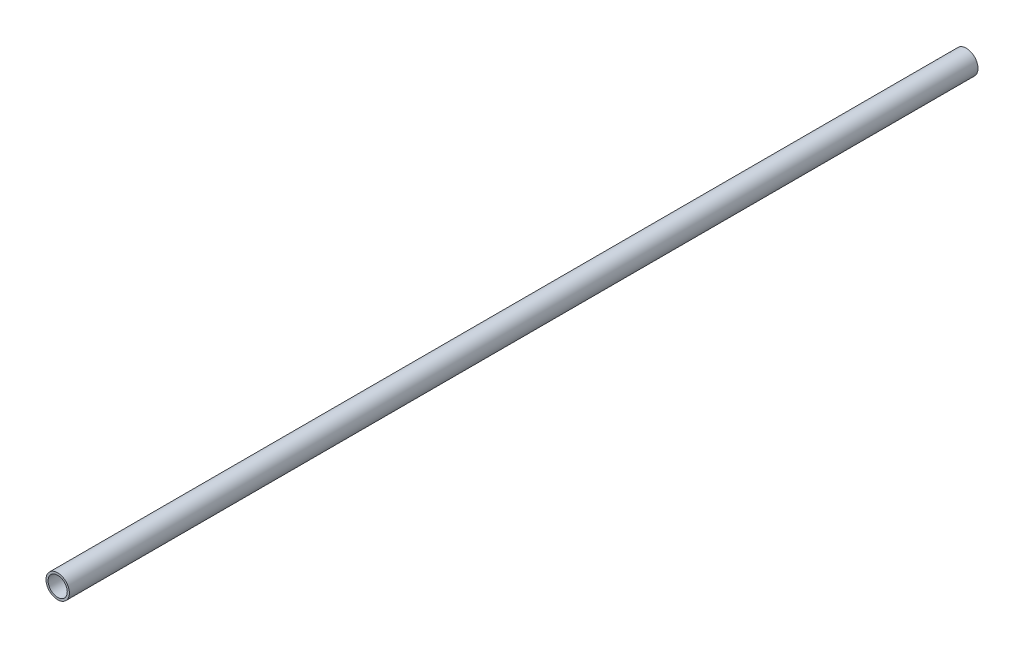
from build123d import *

# Parameters (mm, degrees)
PIPESKETCH_R    = 70.612
PIPESKETCH_R_2  = 57.912
EXTRUSION_DEPTH = 5486.4


with BuildPart() as part:
    # PipeSketch → Extrusion (new body)
    with BuildSketch(Plane.XY):
        Circle(PIPESKETCH_R)
        Circle(PIPESKETCH_R_2, mode=Mode.SUBTRACT)
    extrude(amount=EXTRUSION_DEPTH)


solid = part.part
